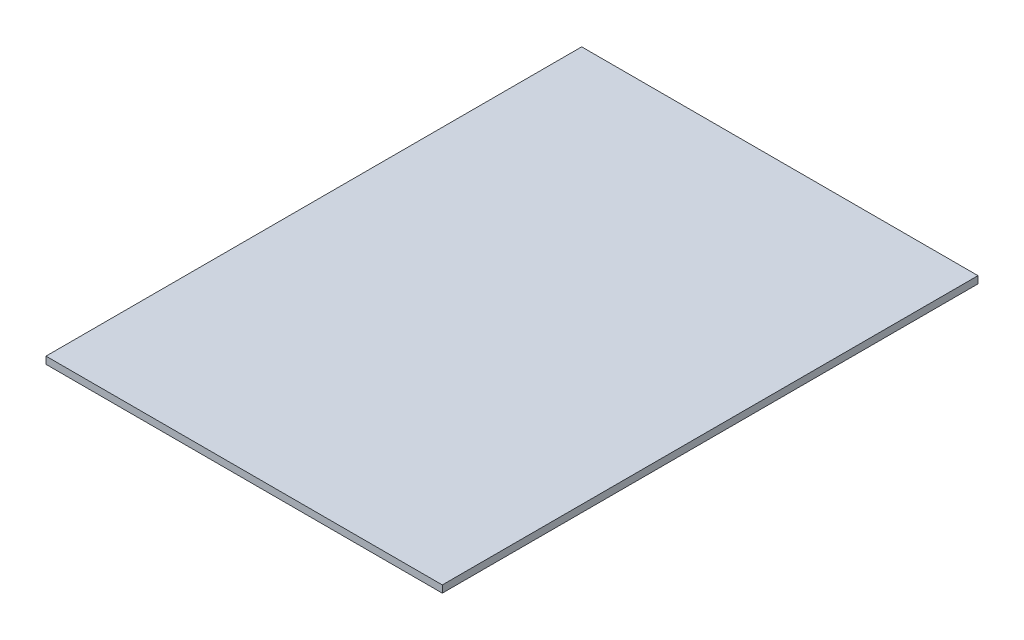
from build123d import *

# Parameters (mm, degrees)
SKETCH1_W           = 2111.756
SKETCH1_H           = 2854.452
BOSS_EXTRUDE1_DEPTH = 38.1


with BuildPart() as part:
    # Sketch1 → Boss-Extrude1 (new body)
    with BuildSketch(Plane(origin=(0, 0, 0), x_dir=(1, 0, 0), z_dir=(0, 1, 0))):
        Rectangle(SKETCH1_W, SKETCH1_H)
    extrude(amount=BOSS_EXTRUDE1_DEPTH)


solid = part.part
